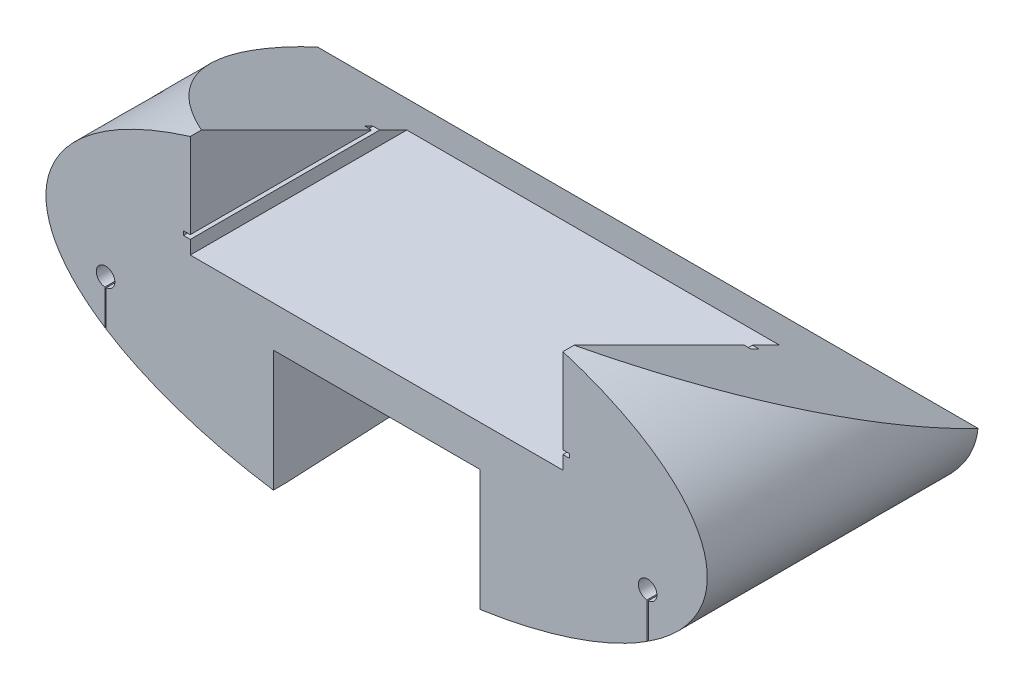
from build123d import *

# Parameters (mm, degrees)
SKETCH1_RX               = 244
SKETCH1_RY               = 110
BOSS_EXTRUDE1_DEPTH      = 200
SKETCH12_R               = 6.83635542
CUT_EXTRUDE8_DEPTH       = 201
CUT_EXTRUDE10_DEPTH      = 245
CUT_EXTRUDE10_DEPTH_BACK = 245
CUT_EXTRUDE11_DEPTH      = 1.0000001
CUT_EXTRUDE11_DEPTH_BACK = 201.0000001
SKETCH17_W               = 152.4
SKETCH17_H               = 90
CUT_EXTRUDE12_DEPTH      = 1.0000001
CUT_EXTRUDE12_DEPTH_BACK = 201.0000001
SKETCH18_W               = 1
SKETCH18_H               = 33.332943991
CUT_EXTRUDE13_DEPTH      = 1.0000001
CUT_EXTRUDE13_DEPTH_BACK = 201.0000001


with BuildPart() as part:
    # Sketch1 → Boss-Extrude1 (new body)
    with BuildSketch(Plane.XY):
        with Locations((0, 0)):
            Ellipse(SKETCH1_RX, SKETCH1_RY)
    extrude(amount=-BOSS_EXTRUDE1_DEPTH)

    # Sketch12 → Cut-Extrude8 (cut, through all)
    with BuildSketch(Plane.XY):
        with Locations((200, -30)):
            Circle(SKETCH12_R)
        with Locations((-200, -30)):
            Circle(SKETCH12_R)
    extrude(amount=-CUT_EXTRUDE8_DEPTH, mode=Mode.SUBTRACT)

    # Sketch15 → Cut-Extrude10 (cut, two sides)
    with BuildSketch(Plane(origin=(0, 0, 0), x_dir=(0, 0, -1), z_dir=(1, 0, 0))) as cut_extrude10_sk:
        Polygon((0, 110), (0, 95), (200, -5), (200, 110), align=None)
        Polygon((0, -110), (200, -110), (200, -95), (0, -105), align=None)
    extrude(amount=CUT_EXTRUDE10_DEPTH, mode=Mode.SUBTRACT)
    extrude(cut_extrude10_sk.sketch, amount=-CUT_EXTRUDE10_DEPTH_BACK, mode=Mode.SUBTRACT)

    # Sketch16 → Cut-Extrude11 (cut, two sides)
    with BuildSketch(Plane.XY) as cut_extrude11_sk:
        Polygon((-137.5, 95), (137.5, 95), (137.5, 28.1), (142.5, 28.1), (142.5, 25.1), (137.5, 25.1), (137.5, 15.1), (-137.5, 15.1), (-137.5, 25.1), (-142.5, 25.1), (-142.5, 28.1), (-137.5, 28.1), align=None)
    extrude(amount=CUT_EXTRUDE11_DEPTH, mode=Mode.SUBTRACT)
    extrude(cut_extrude11_sk.sketch, amount=-CUT_EXTRUDE11_DEPTH_BACK, mode=Mode.SUBTRACT)

    # Sketch17 → Cut-Extrude12 (cut, two sides)
    with BuildSketch(Plane.XY) as cut_extrude12_sk:
        with Locations((0, -60)):
            Rectangle(SKETCH17_W, SKETCH17_H)
    extrude(amount=CUT_EXTRUDE12_DEPTH, mode=Mode.SUBTRACT)
    extrude(cut_extrude12_sk.sketch, amount=-CUT_EXTRUDE12_DEPTH_BACK, mode=Mode.SUBTRACT)

    # Sketch18 → Cut-Extrude13 (cut, two sides)
    with BuildSketch(Plane.XY) as cut_extrude13_sk:
        with Locations((200, -46.666471996)):
            Rectangle(SKETCH18_W, SKETCH18_H)
        with Locations((-200, -46.666471996)):
            Rectangle(SKETCH18_W, SKETCH18_H)
    extrude(amount=CUT_EXTRUDE13_DEPTH, mode=Mode.SUBTRACT)
    extrude(cut_extrude13_sk.sketch, amount=-CUT_EXTRUDE13_DEPTH_BACK, mode=Mode.SUBTRACT)


solid = part.part
